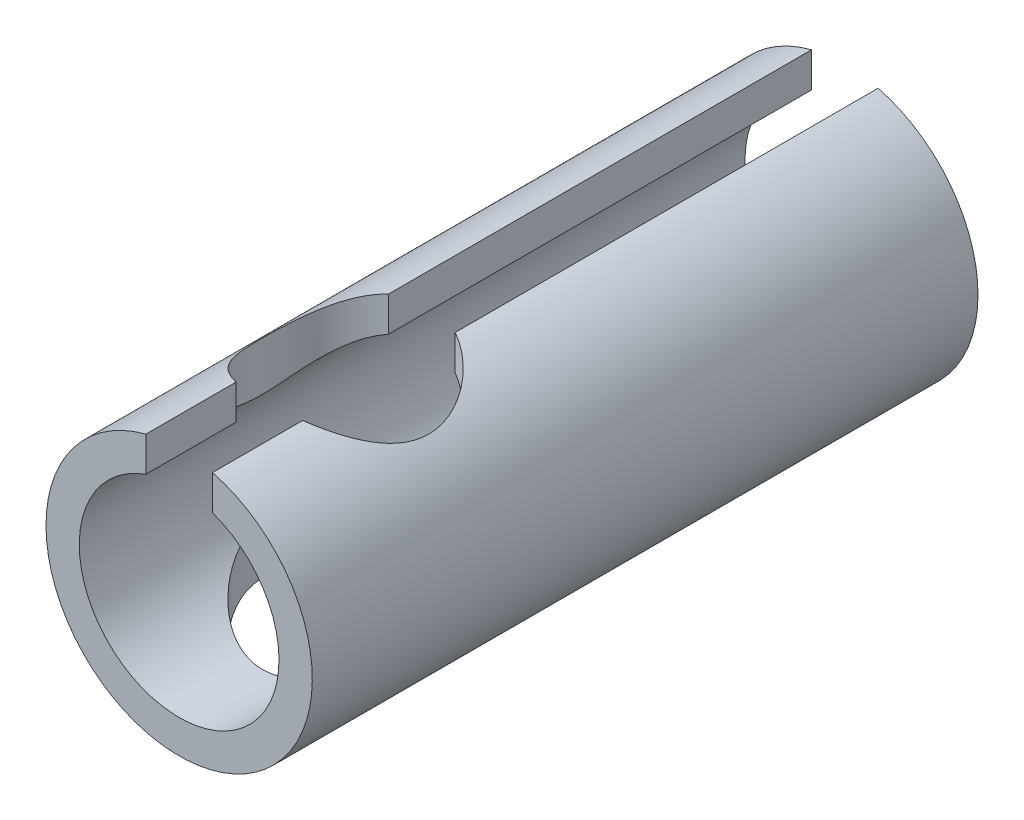
from build123d import *

# Parameters (mm, degrees)
BOSS_EXTRUDE2_DEPTH = 50.8
CUT_EXTRUDE2_START  = -10.16
SKETCH2_R           = 6.35
CUT_EXTRUDE2_DEPTH  = 19.997379


with BuildPart() as part:
    # Sketch1 → Boss-Extrude2 (new body)
    with BuildSketch(Plane.XY):
        with BuildLine():
            Line((-2.54, 7.184204897), (-2.54, 9.837377699))
            ThreePointArc((-2.54, 9.837377699), (-6.221703947, -8.032185257), (10.16, 0))
            ThreePointArc((10.16, 0), (8.032185257, 6.221703947), (2.54, 9.837377699))
            Line((2.54, 9.837377699), (2.54, 7.184204897))
            ThreePointArc((2.54, 7.184204897), (6.221703947, 4.399409051), (7.62, 0))
            ThreePointArc((7.62, 0), (-4.399409051, -6.221703947), (-2.54, 7.184204897))
        make_face()
    extrude(amount=BOSS_EXTRUDE2_DEPTH)

    # Sketch2 → Cut-Extrude2 (cut)
    with BuildSketch(Plane(origin=(0, 0, 0), x_dir=(1, 0, 0), z_dir=(0, 1, 0)).offset(CUT_EXTRUDE2_START)):
        with Locations(Location((0, -38.1, 0), (0, 0, 270))):  # turned: the seam where the file's is
            Circle(SKETCH2_R)
    extrude(amount=CUT_EXTRUDE2_DEPTH, mode=Mode.SUBTRACT)


solid = part.part
